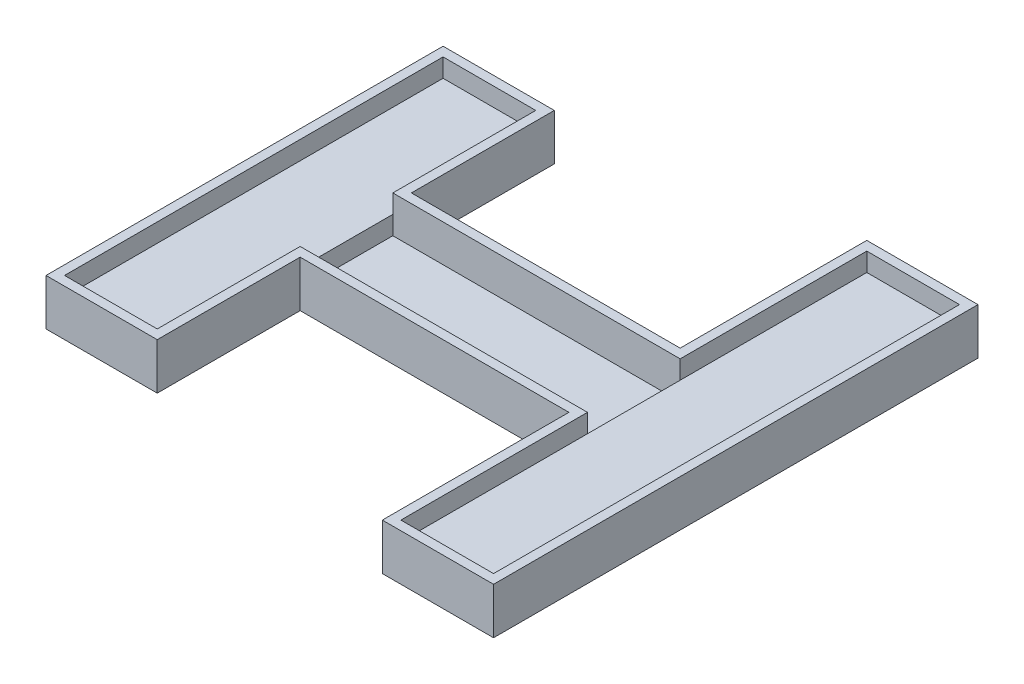
from build123d import *

# Parameters (mm, degrees)
SKETCH_1_W           = 10
SKETCH_1_H           = 15.42
SKETCH_1_H_2         = 10
SKETCH_1_W_2         = 31
SKETCH_1_H_3         = 20.133
EXTRUDE_1_DEPTH      = 1
EXTRUDE_2_DEPTH      = 4
EXTRUDE_2_DEPTH_BACK = 1
SKETCH_3_W           = 10
SKETCH_3_H           = 40.84
SKETCH_3_H_2         = 50.266
EXTRUDE_3_DEPTH      = 2


with BuildPart() as part:
    # 草图1 → 凸台-拉伸1 (new body)
    with BuildSketch(Plane(origin=(0, 0, 0), x_dir=(1, 0, 0), z_dir=(0, 1, 0))):
        with Locations((-20.5, 12.71)):
            Rectangle(SKETCH_1_W, SKETCH_1_H)
        with Locations((-20.5, 0)):
            Rectangle(SKETCH_1_W, SKETCH_1_H_2)
        with Locations((-20.5, -12.71)):
            Rectangle(SKETCH_1_W, SKETCH_1_H)
        Rectangle(SKETCH_1_W_2, SKETCH_1_H_2)
        with Locations((20.5, 15.0665)):
            Rectangle(SKETCH_1_W, SKETCH_1_H_3)
        with Locations((20.5, 0)):
            Rectangle(SKETCH_1_W, SKETCH_1_H_2)
        with Locations((20.5, -15.0665)):
            Rectangle(SKETCH_1_W, SKETCH_1_H_3)
    extrude(amount=EXTRUDE_1_DEPTH)



with BuildPart() as body_2:
    # 草图2 → 凸台-拉伸2 (new body, two sides)
    with BuildSketch(Plane(origin=(0, 1, 0), x_dir=(1, 0, 0), z_dir=(0, 1, 0))) as extrude_2_sk:
        Polygon((-26.5, 21.42), (-26.5, -21.42), (-14.5, -21.42), (-14.5, -6), (14.5, -6), (14.5, -26.133), (26.5, -26.133), (26.5, 26.133), (14.5, 26.133), (14.5, 6), (-14.5, 6), (-14.5, 21.42), align=None)
        Polygon((-15.5, -5), (15.5, -5), (15.5, -25.133), (25.5, -25.133), (25.5, 25.133), (15.5, 25.133), (15.5, 5), (-15.5, 5), (-15.5, 20.42), (-25.5, 20.42), (-25.5, -20.42), (-15.5, -20.42), align=None, mode=Mode.SUBTRACT)
    extrude(amount=EXTRUDE_2_DEPTH)
    extrude(extrude_2_sk.sketch, amount=-EXTRUDE_2_DEPTH_BACK)


with BuildPart() as part_1:
    add(part.part)

    add(body_2.part)  # 凸台-拉伸3 merges body 2
    # 草图3 → 凸台-拉伸3 (add)
    with BuildSketch(Plane(origin=(0, 1, 0), x_dir=(1, 0, 0), z_dir=(0, 1, 0))):
        with Locations((-20.5, 0)):
            Rectangle(SKETCH_3_W, SKETCH_3_H)
        with Locations((20.5, 0)):
            Rectangle(SKETCH_3_W, SKETCH_3_H_2)
    extrude(amount=EXTRUDE_3_DEPTH)


solid = part_1.part
